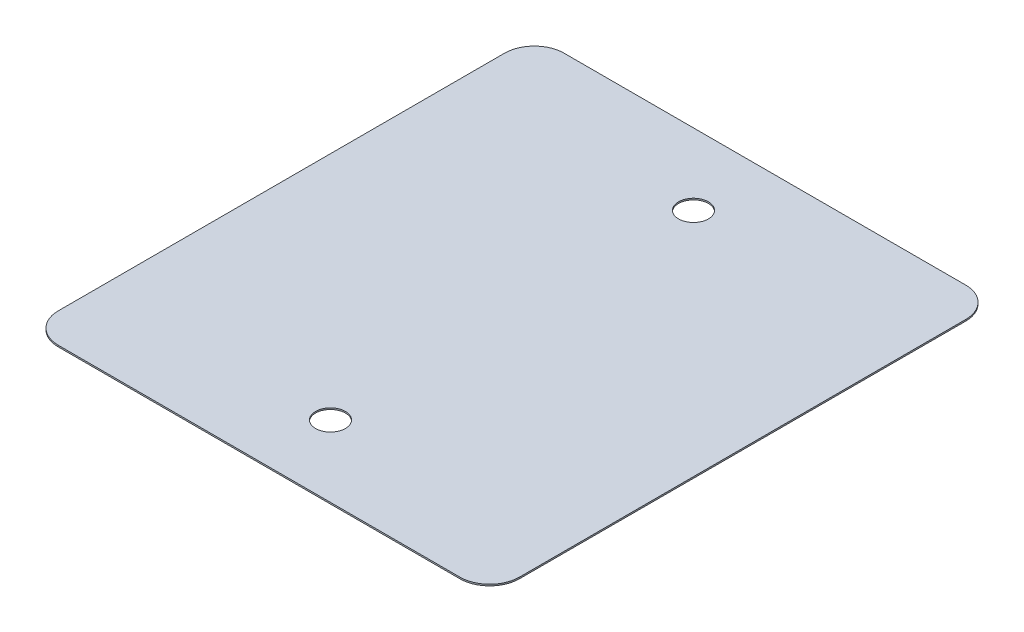
from build123d import *

# Parameters (mm, degrees)
SKETCH1_W           = 15.5
SKETCH1_H           = 17
BOSS_EXTRUDE1_DEPTH = 0.05
FILLET1_R           = 1
SKETCH2_R           = 0.5
CUT_EXTRUDE1_DEPTH  = 1.05


with BuildPart() as part:
    # Sketch1 → Boss-Extrude1 (new body)
    with BuildSketch(Plane(origin=(0, 0, 0), x_dir=(1, 0, 0), z_dir=(0, 1, 0))):
        Rectangle(SKETCH1_W, SKETCH1_H)
    extrude(amount=BOSS_EXTRUDE1_DEPTH)

    # Fillet1
    fillet1_edges = [part.edges().sort_by_distance(p)[0] for p in [
        (-7.75, 0.025, -8.5),
        (7.75, 0.025, -8.5),
        (7.75, 0.025, 8.5),
        (-7.75, 0.025, 8.5),
    ]]
    fillet(fillet1_edges, radius=FILLET1_R)

    # Sketch2 → Cut-Extrude1 (cut, through all)
    with BuildSketch(Plane(origin=(0, 0.05, 0), x_dir=(1, 0, 0), z_dir=(0, 1, 0))):
        with Locations(Location((0, 6.1, 0), (0, 0, 270))):  # turned: the seam where the file's is
            Circle(SKETCH2_R)
        with Locations(Location((0, -6.1, 0), (0, 0, 90))):  # turned: the seam where the file's is
            Circle(SKETCH2_R)
    extrude(amount=-CUT_EXTRUDE1_DEPTH, mode=Mode.SUBTRACT)


solid = part.part
